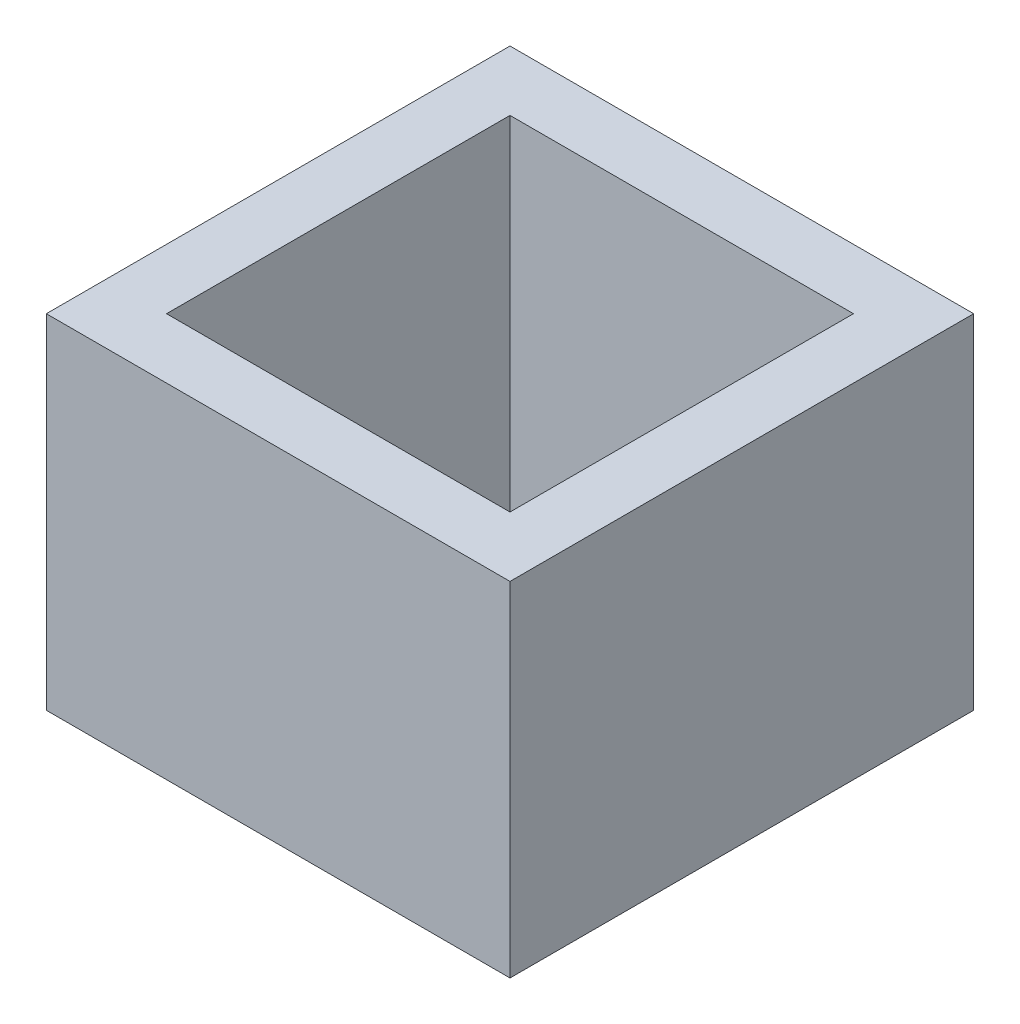
from build123d import *

# Parameters (mm, degrees)
SKETCH1_W           = 13.5
SKETCH1_H           = 13.5
SKETCH1_W_2         = 10
SKETCH1_H_2         = 10
BOSS_EXTRUDE1_DEPTH = 10


with BuildPart() as part:
    # Sketch1 → Boss-Extrude1 (new body)
    with BuildSketch(Plane(origin=(0, 0, 0), x_dir=(1, 0, 0), z_dir=(0, 1, 0))):
        Rectangle(SKETCH1_W, SKETCH1_H)
        Rectangle(SKETCH1_W_2, SKETCH1_H_2, mode=Mode.SUBTRACT)
    extrude(amount=BOSS_EXTRUDE1_DEPTH)


solid = part.part
